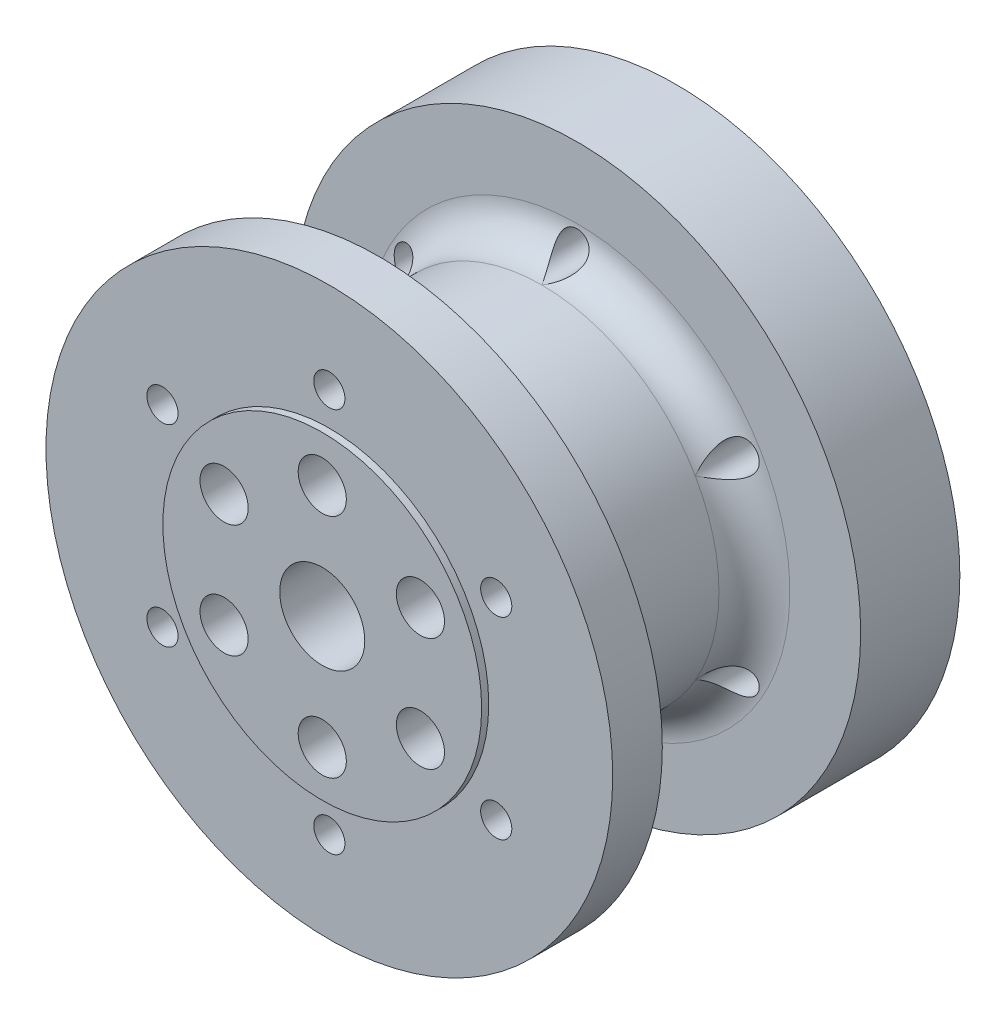
from build123d import *

# Parameters (mm, degrees)
ESBO_O2_R                        = 1.6
CORTE_EXTRUS_O1_DEPTH            = 28
REBAIXO_PARA_SHCS_M31_AT_2_COUNT = 2
REBAIXO_PARA_SHCS_M31_AT_2_PITCH = 8
REBAIXO_PARA_SHCS_M31_AT_3_COUNT = 2
REBAIXO_PARA_SHCS_M31_AT_3_PITCH = 13.856406
REBAIXO_PARA_SHCS_M31_AT_4_COUNT = 2
REBAIXO_PARA_SHCS_M31_AT_4_PITCH = 16
REBAIXO_PARA_SHCS_M31_AT_5_COUNT = 2
REBAIXO_PARA_SHCS_M31_AT_5_PITCH = 13.856406
REBAIXO_PARA_SHCS_M31_AT_6_COUNT = 2
REBAIXO_PARA_SHCS_M31_AT_6_PITCH = 8
ESBO_O5_R                        = 11.275
CORTE_EXTRUS_O2_DEPTH            = 4
FILETE1_R                        = 2.5
ESBO_O6_R                        = 1.1
CORTE_EXTRUS_O3_DEPTH            = 1
CORTE_EXTRUS_O3_DEPTH_BACK       = 28
ESBO_O7_R                        = 16.5
CORTE_EXTRUS_O4_DEPTH            = 4
ESBO_O10_R                       = 5
ESBO_O10_R_2                     = 3
RESSALTO_EXTRUS_O3_DEPTH         = 7
ESBO_O11_R                       = 20
ESBO_O11_R_2                     = 16.5
CORTE_EXTRUS_O6_DEPTH            = 1
ESBO_O12_R                       = 11.25
CORTE_EXTRUS_O7_DEPTH            = 1


with BuildPart() as part:
    # Esboço1 → Revolução1 (revolve)
    with BuildSketch(Plane(origin=(0, 0, 0), x_dir=(0, 0, -1), z_dir=(1, 0, 0))):
        Polygon((1.5, 11.25), (1.5, 20), (5, 20), (5, 12.5), (19, 12.5), (19, 20), (27, 20), (27, 3), (0, 3), (0, 11.25), align=None)
    revolve(axis=Axis((0, 0, 0), (0, 0, -1)))

    # Esboço2 → Corte-extrusão1 (cut, through all)
    with BuildSketch(Plane(origin=(0, 0, -27), x_dir=(-1, 0, 0), z_dir=(0, 0, -1))):
        with Locations((0, 8)):
            Circle(ESBO_O2_R)
        with Locations((6.928203, 4)):
            Circle(ESBO_O2_R)
        with Locations((6.928203, -4)):
            Circle(ESBO_O2_R)
        with Locations((0, -8)):
            Circle(ESBO_O2_R)
        with Locations((-6.928203, -4)):
            Circle(ESBO_O2_R)
        with Locations((-6.928203, 4)):
            Circle(ESBO_O2_R)
    extrude(amount=-CORTE_EXTRUS_O1_DEPTH, mode=Mode.SUBTRACT)

    # Esboço4 → Rebaixo para SHCS M31 (revolve, cut)
    with BuildSketch(Plane(origin=(0, 8, -27), x_dir=(0, 1, 0), z_dir=(1, 0, 0))):
        Polygon((0, 0), (0, 27), (1.7, 27), (1.7, 4), (3.25, 4), (3.25, 0.025), (3.275, 0), align=None)
    rebaixo_para_shcs_m31 = revolve(axis=Axis((0, 8, -33.35), (0, 0, 1)), mode=Mode.SUBTRACT)

    # Rebaixo para SHCS M31 at 2: Rebaixo para SHCS M31 ×2
    with Locations(*[Vector(0.866025, -0.5, 0) * (i * REBAIXO_PARA_SHCS_M31_AT_2_PITCH) for i in range(1, REBAIXO_PARA_SHCS_M31_AT_2_COUNT)]):
        add(rebaixo_para_shcs_m31, mode=Mode.SUBTRACT)

    # Rebaixo para SHCS M31 at 3: Rebaixo para SHCS M31 ×2
    with Locations(*[Vector(0.5, -0.866025, 0) * (i * REBAIXO_PARA_SHCS_M31_AT_3_PITCH) for i in range(1, REBAIXO_PARA_SHCS_M31_AT_3_COUNT)]):
        add(rebaixo_para_shcs_m31, mode=Mode.SUBTRACT)

    # Rebaixo para SHCS M31 at 4: Rebaixo para SHCS M31 ×2
    with Locations(*[(0, -i * REBAIXO_PARA_SHCS_M31_AT_4_PITCH, 0) for i in range(1, REBAIXO_PARA_SHCS_M31_AT_4_COUNT)]):
        add(rebaixo_para_shcs_m31, mode=Mode.SUBTRACT)

    # Rebaixo para SHCS M31 at 5: Rebaixo para SHCS M31 ×2
    with Locations(*[Vector(-0.5, -0.866025, 0) * (i * REBAIXO_PARA_SHCS_M31_AT_5_PITCH) for i in range(1, REBAIXO_PARA_SHCS_M31_AT_5_COUNT)]):
        add(rebaixo_para_shcs_m31, mode=Mode.SUBTRACT)

    # Rebaixo para SHCS M31 at 6: Rebaixo para SHCS M31 ×2
    with Locations(*[Vector(-0.866025, -0.5, 0) * (i * REBAIXO_PARA_SHCS_M31_AT_6_PITCH) for i in range(1, REBAIXO_PARA_SHCS_M31_AT_6_COUNT)]):
        add(rebaixo_para_shcs_m31, mode=Mode.SUBTRACT)

    # Esboço5 → Corte-extrusão2 (cut)
    with BuildSketch(Plane(origin=(0, 0, -27), x_dir=(-1, 0, 0), z_dir=(0, 0, -1))):
        Circle(ESBO_O5_R)
    extrude(amount=-CORTE_EXTRUS_O2_DEPTH, mode=Mode.SUBTRACT)

    # Filete1
    filete1_edges = [part.edges().sort_by_distance(p)[0] for p in [
        (0, -12.5, -5),
        (0, -12.5, -19),
    ]]
    fillet(filete1_edges, radius=FILETE1_R)

    # Esboço6 → Corte-extrusão3 (cut, two sides)
    with BuildSketch(Plane(origin=(0, 0, -27), x_dir=(-1, 0, 0), z_dir=(0, 0, -1))) as corte_extrus_o3_sk:
        with Locations((0, -13.6)):
            Circle(ESBO_O6_R)
        with Locations((-11.777945, -6.8)):
            Circle(ESBO_O6_R)
        with Locations((-11.777945, 6.8)):
            Circle(ESBO_O6_R)
        with Locations((0, 13.6)):
            Circle(ESBO_O6_R)
        with Locations((11.777945, 6.8)):
            Circle(ESBO_O6_R)
        with Locations((11.777945, -6.8)):
            Circle(ESBO_O6_R)
    extrude(amount=CORTE_EXTRUS_O3_DEPTH, mode=Mode.SUBTRACT)
    extrude(corte_extrus_o3_sk.sketch, amount=-CORTE_EXTRUS_O3_DEPTH_BACK, mode=Mode.SUBTRACT)

    # Esboço7 → Corte-extrusão4 (cut)
    with BuildSketch(Plane(origin=(0, 0, -27), x_dir=(-1, 0, 0), z_dir=(0, 0, -1))):
        Circle(ESBO_O7_R)
    extrude(amount=-CORTE_EXTRUS_O4_DEPTH, mode=Mode.SUBTRACT)

    # Esboço10 → Ressalto-extrusão3 (add)
    with BuildSketch(Plane(origin=(0, 0, -23), x_dir=(-1, 0, 0), z_dir=(0, 0, -1))):
        Circle(ESBO_O10_R)
        Circle(ESBO_O10_R_2, mode=Mode.SUBTRACT)
    extrude(amount=RESSALTO_EXTRUS_O3_DEPTH)

    # Esboço11 → Corte-extrusão6 (cut)
    with BuildSketch(Plane(origin=(0, 0, -27), x_dir=(-1, 0, 0), z_dir=(0, 0, -1))):
        Circle(ESBO_O11_R)
        Circle(ESBO_O11_R_2, mode=Mode.SUBTRACT)
    extrude(amount=-CORTE_EXTRUS_O6_DEPTH, mode=Mode.SUBTRACT)

    # Esboço12 → Corte-extrusão7 (cut)
    with BuildSketch(Plane.XY):
        Circle(ESBO_O12_R)
    extrude(amount=-CORTE_EXTRUS_O7_DEPTH, mode=Mode.SUBTRACT)


solid = part.part
